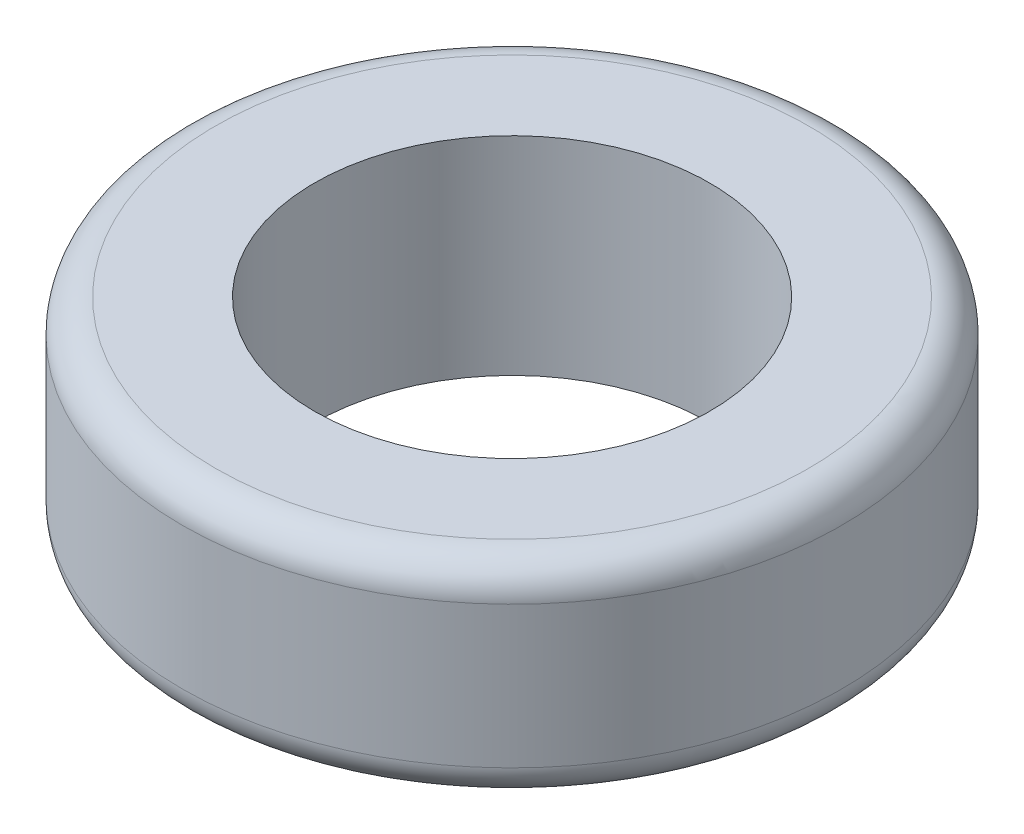
from build123d import *

# Parameters (mm, degrees)
SKETCH1_R           = 10
SKETCH1_R_2         = 6
BOSS_EXTRUDE1_DEPTH = 6.3
FILLET1_R           = 1


with BuildPart() as part:
    # Sketch1 → Boss-Extrude1 (new body)
    with BuildSketch(Plane(origin=(0, 0, 0), x_dir=(1, 0, 0), z_dir=(0, 1, 0))):
        Circle(SKETCH1_R)
        Circle(SKETCH1_R_2, mode=Mode.SUBTRACT)
    extrude(amount=BOSS_EXTRUDE1_DEPTH)

    # Fillet1
    fillet1_edges = [part.edges().sort_by_distance(p)[0] for p in [
        (-10, 0, 0),
        (-10, 6.3, 0),
    ]]
    fillet(fillet1_edges, radius=FILLET1_R)


solid = part.part
